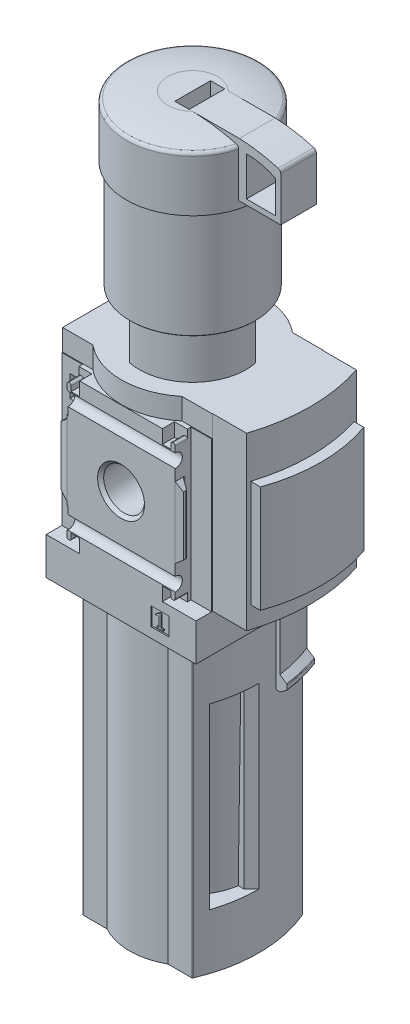
from build123d import *

# Parameters (mm, degrees)
BOSS_EXTRUDE1_DEPTH      = 48
BOSS_EXTRUDE2_DEPTH      = 20.1
BOSS_EXTRUDE2_DEPTH_BACK = 20.1
SKETCH2_W                = 42
SKETCH2_H                = 42
SKETCH3_W                = 42
SKETCH3_H                = 40.2
BOSS_EXTRUDE3_DEPTH      = 10.5
REVOLVE1_ANGLE           = 27
SKETCH5_W                = 55
SKETCH5_H                = 40
CUT_EXTRUDE1_DEPTH       = 82.1
BOSS_EXTRUDE4_DEPTH      = 82.1
CUT_EXTRUDE2_DEPTH       = 50
BOSS_EXTRUDE5_DEPTH      = 48
BOSS_EXTRUDE6_DEPTH      = 30
SKETCH15_W               = 5.1
SKETCH15_H               = 5.1
CUT_EXTRUDE3_DEPTH       = 0.35
SKETCH16_W               = 5.1
SKETCH16_H               = 5.1
CUT_EXTRUDE4_DEPTH       = 0.35
CUT_EXTRUDE5_DEPTH       = 25
CUT_EXTRUDE5_DEPTH_BACK  = 25
CUT_EXTRUDE6_DEPTH       = 25
CUT_EXTRUDE6_DEPTH_BACK  = 25
CUT_EXTRUDE7_DEPTH       = 3.4
CUT_EXTRUDE7_DEPTH_BACK  = 3.4
CUT_EXTRUDE8_DEPTH       = 3.4
CUT_EXTRUDE8_DEPTH_BACK  = 3.4
CUT_EXTRUDE9_DEPTH       = 3.4
CUT_EXTRUDE9_DEPTH_BACK  = 3.4
CUT_EXTRUDE10_DEPTH      = 3.4
CUT_EXTRUDE10_DEPTH_BACK = 3.4
CUT_EXTRUDE11_DEPTH      = 21
CUT_EXTRUDE11_DEPTH_BACK = 21
CUT_EXTRUDE12_DEPTH      = 21
CUT_EXTRUDE12_DEPTH_BACK = 21
SKETCH25_W               = 20
SKETCH25_H               = 10
CUT_EXTRUDE13_DEPTH      = 15
BOSS_EXTRUDE7_DEPTH      = 5
BOSS_EXTRUDE7_DEPTH_BACK = 5
CUT_EXTRUDE14_DEPTH      = 13
CUT_EXTRUDE15_DEPTH      = 22
CUT_EXTRUDE15_DEPTH_BACK = 22
SKETCH28_W               = 3.81
SKETCH28_H               = 6.07
CUT_EXTRUDE16_DEPTH      = 22
CUT_EXTRUDE16_DEPTH_BACK = 22
SKETCH29_W               = 3.81
SKETCH29_H               = 6.07
CUT_EXTRUDE17_DEPTH      = 11
CUT_EXTRUDE17_DEPTH_BACK = 11
SKETCH30_W               = 29
SKETCH30_H               = 37.9
BOSS_EXTRUDE8_DEPTH      = 19
BOSS_EXTRUDE8_DEPTH_BACK = 19
BOSS_EXTRUDE9_DEPTH      = 9
BOSS_EXTRUDE10_DEPTH     = 9
SKETCH34_R               = 3.05
BOSS_EXTRUDE11_DEPTH     = 5


with BuildPart() as part:
    # Sketch1 → Boss-Extrude1 (new body)
    with BuildSketch(Plane(origin=(0, 27, 0), x_dir=(1, 0, 0), z_dir=(0, 1, 0))):
        with BuildLine():
            Line((-21, -15.5), (-12.5, -15.5))
            ThreePointArc((-12.5, -15.5), (0, -20), (12.5, -15.5))
            Line((12.5, -15.5), (21, -15.5))
            Line((21, -15.5), (21, 15.5))
            Line((21, 15.5), (12.5, 15.5))
            ThreePointArc((12.5, 15.5), (0, 20), (-12.5, 15.5))
            Line((-12.5, 15.5), (-21, 15.5))
            Line((-21, 15.5), (-21, -15.5))
        make_face()
    extrude(amount=-BOSS_EXTRUDE1_DEPTH)

    # Sketch2 → Boss-Extrude2 (add, two sides: drawn at the far end of the back side and taken through both)
    with BuildSketch(Plane.XY.offset(-BOSS_EXTRUDE2_DEPTH_BACK)):
        Rectangle(SKETCH2_W, SKETCH2_H)
    extrude(amount=BOSS_EXTRUDE2_DEPTH + BOSS_EXTRUDE2_DEPTH_BACK)

    # Sketch3 → Boss-Extrude3 (add)
    with BuildSketch(Plane(origin=(0, -31.5, 0), x_dir=(1, 0, 0), z_dir=(0, 1, 0))):
        Rectangle(SKETCH3_W, SKETCH3_H)
    extrude(amount=BOSS_EXTRUDE3_DEPTH)

    # Sketch4 → Revolve1 (revolve)
    with BuildSketch(Plane.XY.offset(-0.15)):
        with BuildLine():
            Line((-15.3, -51.69), (19.65, -51.69))
            Line((19.65, -51.69), (21.522072931, -50.379160422))
            ThreePointArc((21.522072931, -50.379160422), (21.61610325, -50.271939392), (21.65, -50.133414808))
            Line((21.65, -50.133414808), (21.65, -49.036585192))
            ThreePointArc((21.65, -49.036585192), (21.61610325, -48.898060608), (21.522072931, -48.790839578))
            Line((21.522072931, -48.790839578), (19.65, -47.48))
            Line((19.65, -47.48), (19.65, -31.5))
            Line((19.65, -31.5), (-15.3, -31.5))
            Line((-15.3, -31.5), (-15.3, -51.69))
        make_face()
    revolve(axis=Axis((-20.3, -51.69, -0.15), (0, 1, 0)), revolution_arc=REVOLVE1_ANGLE)

    # Sketch5 → Cut-Extrude1 (cut)
    with BuildSketch(Plane(origin=(0, -113.6, 0), x_dir=(1, 0, 0), z_dir=(0, 1, 0))):
        with Locations((7.5, 0)):
            Rectangle(SKETCH5_W, SKETCH5_H)
        with BuildLine():
            Line((-14.090696416, -15.5), (-8.546344248, -15.5))
            ThreePointArc((-8.546344248, -15.5), (0, -17.7), (8.546344248, -15.5))
            Line((8.546344248, -15.5), (14.090696416, -15.5))
            ThreePointArc((14.090696416, -15.5), (14.254429483, -15.451379161), (14.36509029, -15.321276552))
            ThreePointArc((14.36509029, -15.321276552), (17.228995904, -5.290034636), (17.249565057, 5.142))
            Line((17.249565057, 5.142), (30, 5.142))
            Line((30, 5.142), (30, 15.349))
            Line((30, 15.349), (14.351078827, 15.349))
            ThreePointArc((14.351078827, 15.349), (14.241195586, 15.459518785), (14.090696416, 15.5))
            Line((14.090696416, 15.5), (8.546344248, 15.5))
            ThreePointArc((8.546344248, 15.5), (0, 17.7), (-8.546344248, 15.5))
            Line((-8.546344248, 15.5), (-14.090696416, 15.5))
            ThreePointArc((-14.090696416, 15.5), (-14.254429483, 15.451379161), (-14.36509029, 15.321276552))
            ThreePointArc((-14.36509029, 15.321276552), (-17.6, -2.4e-08), (-14.365090271, -15.321276596))
            ThreePointArc((-14.365090271, -15.321276596), (-14.254429463, -15.451379174), (-14.090696416, -15.5))
        make_face(mode=Mode.SUBTRACT)
    extrude(amount=CUT_EXTRUDE1_DEPTH, mode=Mode.SUBTRACT)

    # Sketch6 → Boss-Extrude4 (add)
    with BuildSketch(Plane(origin=(0, -113.6, 0), x_dir=(1, 0, 0), z_dir=(0, 1, 0))):
        with BuildLine():
            Line((-15.181262661, -15.5), (-8.546344248, -15.5))
            ThreePointArc((-8.546344248, -15.5), (0, -17.7), (8.546344248, -15.5))
            Line((8.546344248, -15.5), (15.181262661, -15.5))
            ThreePointArc((15.181262661, -15.5), (15.346428602, -15.450440037), (15.457023756, -15.318134746))
            ThreePointArc((15.457023756, -15.318134746), (18.6, -1.7e-08), (15.457023769, 15.318134715))
            ThreePointArc((15.457023769, 15.318134715), (15.346428616, 15.450440027), (15.181262661, 15.5))
            Line((15.181262661, 15.5), (8.546344248, 15.5))
            ThreePointArc((8.546344248, 15.5), (0, 17.7), (-8.546344248, 15.5))
            Line((-8.546344248, 15.5), (-15.181262661, 15.5))
            ThreePointArc((-15.181262661, 15.5), (-15.346428602, 15.450440037), (-15.457023756, 15.318134746))
            ThreePointArc((-15.457023756, 15.318134746), (-18.6, 1.7e-08), (-15.457023769, -15.318134715))
            ThreePointArc((-15.457023769, -15.318134715), (-15.346428616, -15.450440027), (-15.181262661, -15.5))
        make_face()
    extrude(amount=BOSS_EXTRUDE4_DEPTH)

    # Sketch7 → Cut-Revolve1 (revolve, cut)
    with BuildSketch(Plane.XY):
        with BuildLine():
            Line((-30, -112.89), (-30, -113.6))
            Line((-30, -113.6), (-9.987492178, -113.6))
            ThreePointArc((-9.987492178, -113.6), (-12.753297844, -113.283433063), (-15.509219839, -112.89))
            Line((-15.509219839, -112.89), (-30, -112.89))
        make_face()
    revolve(axis=Axis((0, -112.89, 0), (0, -1, 0)), mode=Mode.SUBTRACT)

    # Sketch8 → Cut-Extrude2 (cut)
    with BuildSketch(Plane(origin=(0, -97.39, 0), x_dir=(1, 0, 0), z_dir=(0, 1, 0))):
        Polygon((-22.015432893, -17.312432893), (-14.603, -9.9), (14.603, -9.9), (22.015432893, -17.312432893), (22.015432893, 3.415432893), (16.5, -2.1), (-16.5, -2.1), (-22.015432893, 3.415432893), align=None)
    extrude(amount=CUT_EXTRUDE2_DEPTH, mode=Mode.SUBTRACT)

    # Sketch9 → Revolve2 (revolve)
    with BuildSketch(Plane.XY):
        Polygon((0, -47.39), (15.733, -47.39), (15.0215, -97.39), (0, -97.39), align=None)
    revolve(axis=Axis((0, -97.39, 0), (0, 1, 0)))

    # Sketch10 → Revolve3 (revolve)
    with BuildSketch(Plane.XY):
        with BuildLine():
            Line((0, 87.2), (7, 87.2))
            ThreePointArc((7, 87.2), (12.495494003, 86.643164696), (17.881366679, 85.417238343))
            ThreePointArc((17.881366679, 85.417238343), (18.400426973, 85.057068294), (18.6, 84.457638014))
            Line((18.6, 84.457638014), (18.6, 70))
            Line((18.6, 70), (17.6, 70))
            Line((17.6, 70), (17.6, 40.2))
            Line((17.6, 40.2), (17.4, 40))
            Line((17.4, 40), (15, 40))
            Line((15, 40), (15, 27))
            Line((15, 27), (0, 27))
            Line((0, 27), (0, 87.2))
        make_face()
    revolve(axis=Axis((0, 27, 0), (0, 1, 0)))

    # Sketch11 → Boss-Extrude5 (add)
    with BuildSketch(Plane(origin=(0, 27, 0), x_dir=(1, 0, 0), z_dir=(0, 1, 0))):
        with BuildLine():
            Line((20.9, -15.4), (30.5, -15.4))
            ThreePointArc((30.5, -15.4), (33, 0), (30.5, 15.4))
            Line((30.5, 15.4), (20.9, 15.4))
            Line((20.9, 15.4), (20.9, -15.4))
        make_face()
    extrude(amount=-BOSS_EXTRUDE5_DEPTH)

    # Sketch12 → Boss-Extrude6 (add)
    with BuildSketch(Plane(origin=(0, 15, 0), x_dir=(1, 0, 0), z_dir=(0, 1, 0))):
        with BuildLine():
            Line((26, 14.5), (26, -14.5))
            Line((26, -14.5), (33.5, -14.5))
            ThreePointArc((33.5, -14.5), (36, 0), (33.5, 14.5))
            Line((33.5, 14.5), (26, 14.5))
        make_face()
    extrude(amount=-BOSS_EXTRUDE6_DEPTH)

    # Sketch13 → Cut-Revolve2 (revolve, cut)
    with BuildSketch(Plane(origin=(0, 0, 0), x_dir=(0, 0, -1), z_dir=(1, 0, 0))):
        Polygon((-20.1, 0), (-20.1, 6.5785), (-19.244, 5.7225), (-7.799, 5.7225), (-6.943, 6.5785), (-6.943, 0), align=None)
    revolve(axis=Axis((0, 0, 6.943), (0, 0, 1)), mode=Mode.SUBTRACT)

    # Sketch14 → Cut-Revolve3 (revolve, cut)
    with BuildSketch(Plane(origin=(0, 0, 0), x_dir=(0, 0, -1), z_dir=(1, 0, 0))):
        Polygon((6.943, 0), (6.943, 6.5785), (7.799, 5.7225), (19.244, 5.7225), (20.1, 6.5785), (20.1, 0), align=None)
    revolve(axis=Axis((0, 0, -20.1), (0, 0, 1)), mode=Mode.SUBTRACT)

    # Sketch15 → Cut-Extrude3 (cut)
    with BuildSketch(Plane.XY.offset(20.1)):
        with Locations((10.95, -26.14)):
            Rectangle(SKETCH15_W, SKETCH15_H)
        Polygon((9.663200115, -25.02), (9.761292304, -25.275538889), (10.24, -25.062404491), (10.71, -24.78), (10.71, -27.76), (10.1, -27.76), (10.1, -28.14), (11.8, -28.14), (11.8, -27.76), (11.19, -27.76), (11.19, -24.21), (10.82, -24.21), align=None, mode=Mode.SUBTRACT)
    extrude(amount=-CUT_EXTRUDE3_DEPTH, mode=Mode.SUBTRACT)

    # Sketch16 → Cut-Extrude4 (cut)
    with BuildSketch(Plane.XY.offset(-20.1)):
        with Locations((-10.95, -26.14)):
            Rectangle(SKETCH16_W, SKETCH16_H)
        with BuildLine():
            Line((-12.03983262, -25.241503505), (-10.470570303, -27.482642356))
            ThreePointArc((-10.470570303, -27.482642356), (-10.463784424, -27.586174861), (-10.552485507, -27.64))
            Line((-10.552485507, -27.64), (-12.15, -27.64))
            Line((-12.15, -27.64), (-12.15, -28.14))
            Line((-12.15, -28.14), (-9.75, -28.14))
            Line((-9.75, -28.14), (-9.75, -27.64))
            Line((-9.75, -27.64), (-11.575165094, -25.033394109))
            ThreePointArc((-11.575165094, -25.033394109), (-11.592129791, -24.774562847), (-11.370377083, -24.64))
            Line((-11.370377083, -24.64), (-10.75, -24.64))
            ThreePointArc((-10.75, -24.64), (-10.396446609, -24.786446609), (-10.25, -25.14))
            Line((-10.25, -25.14), (-9.75, -25.14))
            ThreePointArc((-9.75, -25.14), (-10.042893219, -24.432893219), (-10.75, -24.14))
            Line((-10.75, -24.14), (-11.466426189, -24.14))
            ThreePointArc((-11.466426189, -24.14), (-12.087333772, -24.516775971), (-12.03983262, -25.241503505))
        make_face(mode=Mode.SUBTRACT)
    extrude(amount=CUT_EXTRUDE4_DEPTH, mode=Mode.SUBTRACT)

    # Sketch17 → Cut-Extrude5 (cut, two sides: drawn at the far end of the back side and taken through both)
    with BuildSketch(Plane(origin=(0, 0, 0), x_dir=(0, 0, -1), z_dir=(1, 0, 0)).offset(-CUT_EXTRUDE5_DEPTH_BACK)):
        with BuildLine():
            Line((21.9, -15), (21.9, 15))
            ThreePointArc((21.9, 15), (18.490033113, 16.153256259), (20.5, 13.166969722))
            Line((20.5, 13.166969722), (20.5, -13.166969722))
            ThreePointArc((20.5, -13.166969722), (18.490033113, -16.153256259), (21.9, -15))
        make_face()
    extrude(amount=CUT_EXTRUDE5_DEPTH + CUT_EXTRUDE5_DEPTH_BACK, mode=Mode.SUBTRACT)

    # Sketch18 → Cut-Extrude6 (cut, two sides: drawn at the far end of the back side and taken through both)
    with BuildSketch(Plane(origin=(0, 0, 0), x_dir=(0, 0, -1), z_dir=(1, 0, 0)).offset(-CUT_EXTRUDE6_DEPTH_BACK)):
        with BuildLine():
            Line((-21.9, 15), (-21.9, -15))
            ThreePointArc((-21.9, -15), (-18.490033113, -16.153256259), (-20.5, -13.166969722))
            Line((-20.5, -13.166969722), (-20.5, 13.166969722))
            ThreePointArc((-20.5, 13.166969722), (-18.490033113, 16.153256259), (-21.9, 15))
        make_face()
    extrude(amount=CUT_EXTRUDE6_DEPTH + CUT_EXTRUDE6_DEPTH_BACK, mode=Mode.SUBTRACT)

    # Sketch19 → Cut-Extrude7 (cut, two sides: drawn at the far end of the back side and taken through both)
    with BuildSketch(Plane.XY.offset(20.1).offset(-CUT_EXTRUDE7_DEPTH_BACK)):
        with BuildLine():
            Line((11.6, 21), (11.6, 17.2))
            Line((11.6, 17.2), (14, 17.2))
            Line((14, 17.2), (14, 18.6))
            ThreePointArc((14, 18.6), (14.146446609, 18.953553391), (14.5, 19.1))
            Line((14.5, 19.1), (14.7, 19.1))
            ThreePointArc((14.7, 19.1), (15.053553391, 18.953553391), (15.2, 18.6))
            Line((15.2, 18.6), (15.2, 9.95))
            Line((15.2, 9.95), (21.5, 4.663672324))
            Line((21.5, 4.663672324), (21.5, -4.663672324))
            Line((21.5, -4.663672324), (15.2, -9.95))
            Line((15.2, -9.95), (15.2, -18.6))
            ThreePointArc((15.2, -18.6), (15.053553391, -18.953553391), (14.7, -19.1))
            Line((14.7, -19.1), (14.5, -19.1))
            ThreePointArc((14.5, -19.1), (14.146446609, -18.953553391), (14, -18.6))
            Line((14, -18.6), (14, -17.2))
            Line((14, -17.2), (11.6, -17.2))
            Line((11.6, -17.2), (11.6, -21))
            Line((11.6, -21), (22, -21))
            Line((22, -21), (22, 21))
            Line((22, 21), (11.6, 21))
        make_face()
    extrude(amount=CUT_EXTRUDE7_DEPTH + CUT_EXTRUDE7_DEPTH_BACK, mode=Mode.SUBTRACT)

    # Sketch20 → Cut-Extrude8 (cut, two sides: drawn at the far end of the back side and taken through both)
    with BuildSketch(Plane.XY.offset(20.1).offset(-CUT_EXTRUDE8_DEPTH_BACK)):
        with BuildLine():
            Line((-22, -21), (-11.6, -21))
            Line((-11.6, -21), (-11.6, -17.2))
            Line((-11.6, -17.2), (-14, -17.2))
            Line((-14, -17.2), (-14, -18.6))
            ThreePointArc((-14, -18.6), (-14.146446609, -18.953553391), (-14.5, -19.1))
            Line((-14.5, -19.1), (-14.7, -19.1))
            ThreePointArc((-14.7, -19.1), (-15.053553391, -18.953553391), (-15.2, -18.6))
            Line((-15.2, -18.6), (-15.2, -9.95))
            Line((-15.2, -9.95), (-21.5, -4.663672324))
            Line((-21.5, -4.663672324), (-21.5, 4.663672324))
            Line((-21.5, 4.663672324), (-15.2, 9.95))
            Line((-15.2, 9.95), (-15.2, 18.6))
            ThreePointArc((-15.2, 18.6), (-15.053553391, 18.953553391), (-14.7, 19.1))
            Line((-14.7, 19.1), (-14.5, 19.1))
            ThreePointArc((-14.5, 19.1), (-14.146446609, 18.953553391), (-14, 18.6))
            Line((-14, 18.6), (-14, 17.2))
            Line((-14, 17.2), (-11.6, 17.2))
            Line((-11.6, 17.2), (-11.6, 21))
            Line((-11.6, 21), (-22, 21))
            Line((-22, 21), (-22, -21))
        make_face()
    extrude(amount=CUT_EXTRUDE8_DEPTH + CUT_EXTRUDE8_DEPTH_BACK, mode=Mode.SUBTRACT)

    # Sketch21 → Cut-Extrude9 (cut, two sides: drawn at the far end of the back side and taken through both)
    with BuildSketch(Plane.XY.offset(-20.1).offset(-CUT_EXTRUDE9_DEPTH_BACK)):
        with BuildLine():
            Line((11.6, 21), (11.6, 17.2))
            Line((11.6, 17.2), (14, 17.2))
            Line((14, 17.2), (14, 18.6))
            ThreePointArc((14, 18.6), (14.146446609, 18.953553391), (14.5, 19.1))
            Line((14.5, 19.1), (14.7, 19.1))
            ThreePointArc((14.7, 19.1), (15.053553391, 18.953553391), (15.2, 18.6))
            Line((15.2, 18.6), (15.2, 9.95))
            Line((15.2, 9.95), (21.5, 4.663672324))
            Line((21.5, 4.663672324), (21.5, -4.663672324))
            Line((21.5, -4.663672324), (15.2, -9.95))
            Line((15.2, -9.95), (15.2, -18.6))
            ThreePointArc((15.2, -18.6), (15.053553391, -18.953553391), (14.7, -19.1))
            Line((14.7, -19.1), (14.5, -19.1))
            ThreePointArc((14.5, -19.1), (14.146446609, -18.953553391), (14, -18.6))
            Line((14, -18.6), (14, -17.2))
            Line((14, -17.2), (11.6, -17.2))
            Line((11.6, -17.2), (11.6, -21))
            Line((11.6, -21), (22, -21))
            Line((22, -21), (22, 21))
            Line((22, 21), (11.6, 21))
        make_face()
    extrude(amount=CUT_EXTRUDE9_DEPTH + CUT_EXTRUDE9_DEPTH_BACK, mode=Mode.SUBTRACT)

    # Sketch22 → Cut-Extrude10 (cut, two sides: drawn at the far end of the back side and taken through both)
    with BuildSketch(Plane.XY.offset(-20.1).offset(-CUT_EXTRUDE10_DEPTH_BACK)):
        with BuildLine():
            Line((-22, -21), (-11.6, -21))
            Line((-11.6, -21), (-11.6, -17.2))
            Line((-11.6, -17.2), (-14, -17.2))
            Line((-14, -17.2), (-14, -18.6))
            ThreePointArc((-14, -18.6), (-14.146446609, -18.953553391), (-14.5, -19.1))
            Line((-14.5, -19.1), (-14.7, -19.1))
            ThreePointArc((-14.7, -19.1), (-15.053553391, -18.953553391), (-15.2, -18.6))
            Line((-15.2, -18.6), (-15.2, -9.95))
            Line((-15.2, -9.95), (-21.5, -4.663672324))
            Line((-21.5, -4.663672324), (-21.5, 4.663672324))
            Line((-21.5, 4.663672324), (-15.2, 9.95))
            Line((-15.2, 9.95), (-15.2, 18.6))
            ThreePointArc((-15.2, 18.6), (-15.053553391, 18.953553391), (-14.7, 19.1))
            Line((-14.7, 19.1), (-14.5, 19.1))
            ThreePointArc((-14.5, 19.1), (-14.146446609, 18.953553391), (-14, 18.6))
            Line((-14, 18.6), (-14, 17.2))
            Line((-14, 17.2), (-11.6, 17.2))
            Line((-11.6, 17.2), (-11.6, 21))
            Line((-11.6, 21), (-22, 21))
            Line((-22, 21), (-22, -21))
        make_face()
    extrude(amount=CUT_EXTRUDE10_DEPTH + CUT_EXTRUDE10_DEPTH_BACK, mode=Mode.SUBTRACT)

    # Sketch23 → Cut-Extrude11 (cut, two sides: drawn at the far end of the back side and taken through both)
    with BuildSketch(Plane(origin=(0, 0, 0), x_dir=(1, 0, 0), z_dir=(0, 1, 0)).offset(-CUT_EXTRUDE11_DEPTH_BACK)):
        with BuildLine():
            Line((-22.2, 25.1), (-22.2, 15.7))
            Line((-22.2, 15.7), (-15.2, 15.7))
            Line((-15.2, 15.7), (-15.2, 17.400104518))
            ThreePointArc((-15.2, 17.400104518), (-15.321561523, 17.82403993), (-15.649303083, 18.119139756))
            Line((-15.649303083, 18.119139756), (-16.919185573, 18.73850283))
            ThreePointArc((-16.919185573, 18.73850283), (-17.124024048, 18.922940221), (-17.2, 19.187899853))
            Line((-17.2, 19.187899853), (-17.2, 19.8))
            Line((-17.2, 19.8), (-15.2, 20.1))
            Line((-15.2, 20.1), (15.2, 20.1))
            Line((15.2, 20.1), (17.2, 19.8))
            Line((17.2, 19.8), (17.2, 19.187899853))
            ThreePointArc((17.2, 19.187899853), (17.124024048, 18.922940221), (16.919185573, 18.73850283))
            Line((16.919185573, 18.73850283), (15.649303083, 18.119139756))
            ThreePointArc((15.649303083, 18.119139756), (15.321561523, 17.82403993), (15.2, 17.400104518))
            Line((15.2, 17.400104518), (15.2, 15.7))
            Line((15.2, 15.7), (22.2, 15.7))
            Line((22.2, 15.7), (22.2, 25.1))
            Line((22.2, 25.1), (-22.2, 25.1))
        make_face()
    extrude(amount=CUT_EXTRUDE11_DEPTH + CUT_EXTRUDE11_DEPTH_BACK, mode=Mode.SUBTRACT)

    # Sketch24 → Cut-Extrude12 (cut, two sides: drawn at the far end of the back side and taken through both)
    with BuildSketch(Plane(origin=(0, 0, 0), x_dir=(1, 0, 0), z_dir=(0, 1, 0)).offset(-CUT_EXTRUDE12_DEPTH_BACK)):
        with BuildLine():
            Line((-22.2, -15.7), (-22.2, -25.1))
            Line((-22.2, -25.1), (22.2, -25.1))
            Line((22.2, -25.1), (22.2, -15.7))
            Line((22.2, -15.7), (15.2, -15.7))
            Line((15.2, -15.7), (15.2, -17.400104518))
            ThreePointArc((15.2, -17.400104518), (15.321561523, -17.82403993), (15.649303083, -18.119139756))
            Line((15.649303083, -18.119139756), (16.919185573, -18.73850283))
            ThreePointArc((16.919185573, -18.73850283), (17.124024048, -18.922940221), (17.2, -19.187899853))
            Line((17.2, -19.187899853), (17.2, -19.8))
            Line((17.2, -19.8), (15.2, -20.1))
            Line((15.2, -20.1), (-15.2, -20.1))
            Line((-15.2, -20.1), (-17.2, -19.8))
            Line((-17.2, -19.8), (-17.2, -19.187899853))
            ThreePointArc((-17.2, -19.187899853), (-17.124024048, -18.922940221), (-16.919185573, -18.73850283))
            Line((-16.919185573, -18.73850283), (-15.649303083, -18.119139756))
            ThreePointArc((-15.649303083, -18.119139756), (-15.321561523, -17.82403993), (-15.2, -17.400104518))
            Line((-15.2, -17.400104518), (-15.2, -15.7))
            Line((-15.2, -15.7), (-22.2, -15.7))
        make_face()
    extrude(amount=CUT_EXTRUDE12_DEPTH + CUT_EXTRUDE12_DEPTH_BACK, mode=Mode.SUBTRACT)

    # Sketch25 → Cut-Extrude13 (cut)
    with BuildSketch(Plane(origin=(0, 87.2, 0), x_dir=(1, 0, 0), z_dir=(0, 1, 0))):
        with Locations((10, 0)):
            Rectangle(SKETCH25_W, SKETCH25_H)
    extrude(amount=-CUT_EXTRUDE13_DEPTH, mode=Mode.SUBTRACT)

    # Sketch26 → Boss-Extrude7 (add, two sides: drawn at the far end of the back side and taken through both)
    with BuildSketch(Plane.XY.offset(-BOSS_EXTRUDE7_DEPTH_BACK)):
        with BuildLine():
            Line((4, 72), (29.7, 72))
            Line((29.7, 72), (29.7, 84.457638014))
            ThreePointArc((29.7, 84.457638014), (29.500426973, 85.057068294), (28.981366679, 85.417238343))
            ThreePointArc((28.981366679, 85.417238343), (23.595494003, 86.643164696), (18.1, 87.2))
            Line((18.1, 87.2), (4, 87.2))
            Line((4, 87.2), (4, 72))
        make_face()
        with BuildLine():
            Line((20.1, 84.457638014), (20.1, 73.5))
            Line((20.1, 73.5), (28.2, 73.5))
            Line((28.2, 73.5), (28.2, 82.6))
            ThreePointArc((28.2, 82.6), (24.258672399, 84.002671516), (20.1, 84.457638014))
        make_face(mode=Mode.SUBTRACT)
    extrude(amount=BOSS_EXTRUDE7_DEPTH + BOSS_EXTRUDE7_DEPTH_BACK)

    # Sketch27 → Cut-Extrude14 (cut)
    with BuildSketch(Plane(origin=(0, 27, 0), x_dir=(1, 0, 0), z_dir=(0, 1, 0))):
        Polygon((-49.497474683, 7.071067812), (7.071067812, -49.497474683), (49.497474683, -7.071067812), (-7.071067812, 49.497474683), align=None)
        Polygon((-30.0520382, 12.374368671), (12.374368671, -30.0520382), (30.0520382, -12.374368671), (-12.374368671, 30.0520382), align=None, mode=Mode.SUBTRACT)
    extrude(amount=CUT_EXTRUDE14_DEPTH, mode=Mode.SUBTRACT)

    # Sketch28 → Cut-Extrude15 (cut, two sides: drawn at the far end of the back side and taken through both)
    with BuildSketch(Plane.XY.offset(-CUT_EXTRUDE15_DEPTH_BACK)):
        with Locations((-16.825, 14.005)):
            Rectangle(SKETCH28_W, SKETCH28_H)
    extrude(amount=CUT_EXTRUDE15_DEPTH + CUT_EXTRUDE15_DEPTH_BACK, mode=Mode.SUBTRACT)

    # Sketch29 → Cut-Extrude16 (cut, two sides: drawn at the far end of the back side and taken through both)
    with BuildSketch(Plane.XY.offset(-CUT_EXTRUDE16_DEPTH_BACK)):
        with Locations((-16.825, -13.995)):
            Rectangle(SKETCH29_W, SKETCH29_H)
    extrude(amount=CUT_EXTRUDE16_DEPTH + CUT_EXTRUDE16_DEPTH_BACK, mode=Mode.SUBTRACT)

    # Sketch30 → Cut-Extrude17 (cut, two sides: drawn at the far end of the back side and taken through both)
    with BuildSketch(Plane(origin=(-21, 0, 0), x_dir=(0, 0, -1), z_dir=(1, 0, 0)).offset(-CUT_EXTRUDE17_DEPTH_BACK)):
        Rectangle(SKETCH30_W, SKETCH30_H)
    extrude(amount=CUT_EXTRUDE17_DEPTH + CUT_EXTRUDE17_DEPTH_BACK, mode=Mode.SUBTRACT)

    # Sketch31 → Boss-Extrude8 (add, two sides: drawn at the far end of the back side and taken through both)
    with BuildSketch(Plane(origin=(0, 0, 0), x_dir=(1, 0, 0), z_dir=(0, 1, 0)).offset(-BOSS_EXTRUDE8_DEPTH_BACK)):
        with BuildLine():
            Line((-11.489125293, -14.5), (-10, -14.5))
            Line((-10, -14.5), (-10, 14.5))
            Line((-10, 14.5), (-11.489125293, 14.5))
            ThreePointArc((-11.489125293, 14.5), (-18.5, 0), (-11.489125293, -14.5))
        make_face()
    extrude(amount=BOSS_EXTRUDE8_DEPTH + BOSS_EXTRUDE8_DEPTH_BACK)

    # Sketch32 → Boss-Extrude9 (add)
    with BuildSketch(Plane(origin=(-19.9, 0, 0), x_dir=(0, 0, -1), z_dir=(1, 0, 0))):
        with BuildLine():
            Line((8.8, -21.3), (14.6, -21.3))
            Line((14.6, -21.3), (14.6, -17.1))
            Line((14.6, -17.1), (13.163330765, -17.1))
            ThreePointArc((13.163330765, -17.1), (10.799161363, -15.309186489), (8.8, -17.5))
            Line((8.8, -17.5), (8.8, -21.3))
        make_face()
    extrude(amount=BOSS_EXTRUDE9_DEPTH)

    # Sketch33 → Boss-Extrude10 (add)
    with BuildSketch(Plane(origin=(-19.9, 0, 0), x_dir=(0, 0, -1), z_dir=(1, 0, 0))):
        with BuildLine():
            Line((-14.6, 17.1), (-13.163330765, 17.1))
            ThreePointArc((-13.163330765, 17.1), (-10.799161363, 15.309186489), (-8.8, 17.5))
            Line((-8.8, 17.5), (-8.8, 21.3))
            Line((-8.8, 21.3), (-14.6, 21.3))
            Line((-14.6, 21.3), (-14.6, 17.1))
        make_face()
    extrude(amount=BOSS_EXTRUDE10_DEPTH)

    # Sketch34 → Boss-Extrude11 (add)
    with BuildSketch(Plane(origin=(-18, 0, 0), x_dir=(0, 0, -1), z_dir=(1, 0, 0))):
        with Locations((8.6, 6)):
            Circle(SKETCH34_R)
    extrude(amount=BOSS_EXTRUDE11_DEPTH)


solid = part.part
